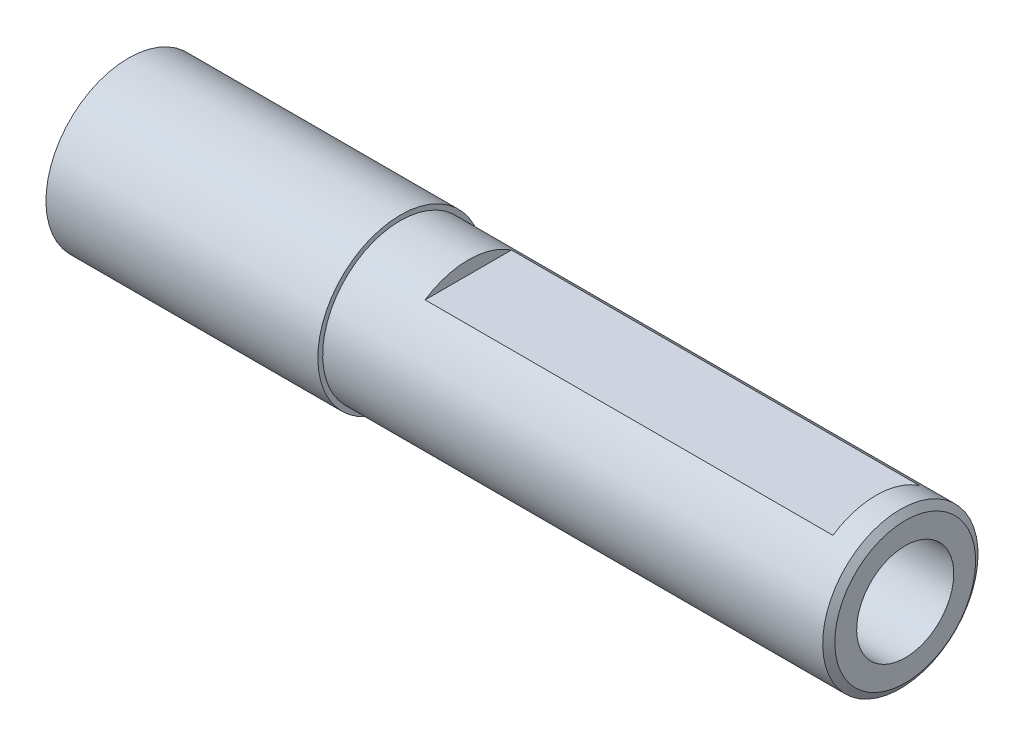
from build123d import *

# Parameters (mm, degrees)
SKETCH2_W               = 42
SKETCH2_H               = 1.35
CUT_EXTRUDE1_DEPTH      = 10
CUT_EXTRUDE1_DEPTH_BACK = 10
SKETCH3_R               = 5
CUT_EXTRUDE2_DEPTH      = 79.475065146


with BuildPart() as part:
    # Sketch1 → Revolve1 (revolve)
    with BuildSketch(Plane.XY):
        Polygon((7, 8), (49, 8), (51.5, 8), (52, 7.25069297), (52, 0), (-28, 0), (-28, 8.5), (0, 8.5), (0, 8), align=None)
    revolve(axis=Axis((52, 0, 0), (-1, 0, 0)))

    # Sketch2 → Cut-Extrude1 (cut, two sides)
    with BuildSketch(Plane.XY) as cut_extrude1_sk:
        with Locations((28, 7.325)):
            Rectangle(SKETCH2_W, SKETCH2_H)
    extrude(amount=CUT_EXTRUDE1_DEPTH, mode=Mode.SUBTRACT)
    extrude(cut_extrude1_sk.sketch, amount=-CUT_EXTRUDE1_DEPTH_BACK, mode=Mode.SUBTRACT)

    # Sketch3 → Cut-Extrude2 (cut)
    with BuildSketch(Plane(origin=(52, 0, 0), x_dir=(0, 0, -1), z_dir=(1, 0, 0))):
        with Locations(Location((0, 0, 0), (0, 0, 90))):  # turned: the seam where the file's is
            Circle(SKETCH3_R)
    extrude(amount=-CUT_EXTRUDE2_DEPTH, mode=Mode.SUBTRACT)


solid = part.part
